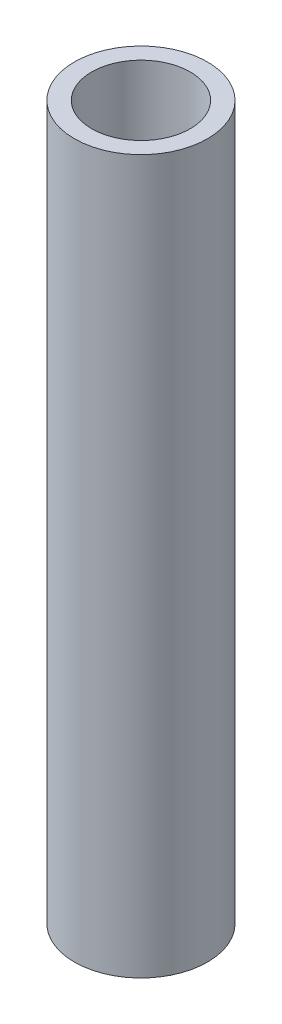
from build123d import *

# Parameters (mm, degrees)
SKETCH1_R           = 10.668
SKETCH1_R_2         = 7.8994
BOSS_EXTRUDE1_DEPTH = 114.3


with BuildPart() as part:
    # Sketch1 → Boss-Extrude1 (new body)
    with BuildSketch(Plane(origin=(0, 0, 0), x_dir=(1, 0, 0), z_dir=(0, 1, 0))):
        Circle(SKETCH1_R)
        Circle(SKETCH1_R_2, mode=Mode.SUBTRACT)
    extrude(amount=BOSS_EXTRUDE1_DEPTH)


solid = part.part
